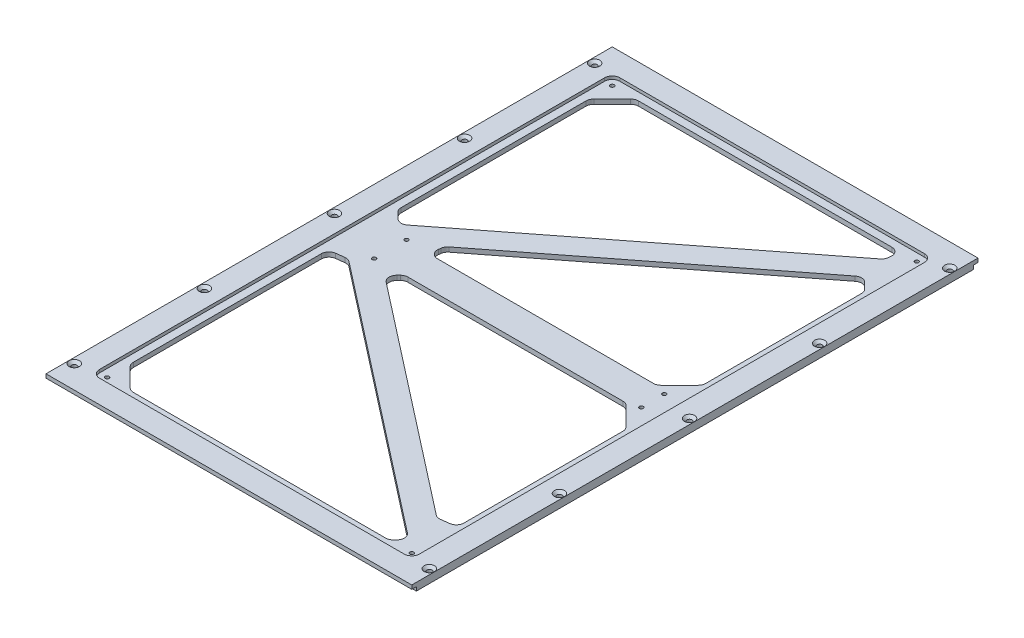
from build123d import *
from OCP.BRepFilletAPI import BRepFilletAPI_MakeChamfer

# Parameters (mm, degrees)
SKETCH1_W                                            = 239
SKETCH1_H                                            = 370
BOSS_EXTRUDE1_DEPTH                                  = 5
CSK_FOR_M3_HEX_SOCKET_COUNTERSUNK_CAP_SC_D           = 3.4
CSK_FOR_M3_HEX_SOCKET_COUNTERSUNK_CAP_SC_CSINK_D     = 6.72
CSK_FOR_M3_HEX_SOCKET_COUNTERSUNK_CAP_SC_CSINK_ANGLE = 90
SKETCH12_W                                           = 239
SKETCH12_H                                           = 3
CUT_EXTRUDE7_DEPTH                                   = 2.5
CUT_EXTRUDE8_DEPTH                                   = 441.506526626
CHAMFER1_SIZE                                        = 15
CHAMFER1_SIZE2                                       = 10.688218108
FILLET1_R                                            = 5
SKETCH14_W                                           = 209
SKETCH14_H                                           = 340
CUT_EXTRUDE9_DEPTH                                   = 2
FILLET2_R                                            = 5
M3_TAPPED_HOLE1_D                                    = 2.5
M3_TAPPED_HOLE1_DEPTH                                = 15
M3_TAPPED_HOLE1_TIP                                  = 0.751075774


with BuildPart() as part:
    # Sketch1 → Boss-Extrude1 (new body)
    with BuildSketch(Plane(origin=(0, 0, 0), x_dir=(1, 0, 0), z_dir=(0, 1, 0))):
        with Locations((-119.5, 185)):
            Rectangle(SKETCH1_W, SKETCH1_H)
    extrude(amount=BOSS_EXTRUDE1_DEPTH)

    # CSK for M3 Hex Socket Countersunk Cap Screw1 (through all)
    with Locations(Plane(origin=(0, 5, 0), x_dir=(1, 0, 0), z_dir=(0, 1, 0))):
        with Locations((-3.5, 15), (-3.5, 100), (-3.5, 185), (-3.5, 270), (-3.5, 355)):
            csk_for_m3_hex_socket_countersunk_cap_sc = CounterSinkHole(CSK_FOR_M3_HEX_SOCKET_COUNTERSUNK_CAP_SC_D / 2, CSK_FOR_M3_HEX_SOCKET_COUNTERSUNK_CAP_SC_CSINK_D / 2, counter_sink_angle=CSK_FOR_M3_HEX_SOCKET_COUNTERSUNK_CAP_SC_CSINK_ANGLE)

    # Mirror1: CSK for M3 Hex Socket Countersunk Cap Screw1 across plane
    add(csk_for_m3_hex_socket_countersunk_cap_sc.mirror(Plane.ZY.offset(119.5)), mode=Mode.SUBTRACT)

    # Sketch12 → Cut-Extrude7 (cut)
    with BuildSketch(Plane.XZ):
        with Locations((-119.5, -1.5)):
            Rectangle(SKETCH12_W, SKETCH12_H)
        with Locations((-119.5, -368.5)):
            Rectangle(SKETCH12_W, SKETCH12_H)
    extrude(amount=-CUT_EXTRUDE7_DEPTH, mode=Mode.SUBTRACT)

    # Sketch13 → Cut-Extrude8 (cut, through all)
    with BuildSketch(Plane(origin=(0, 5, 0), x_dir=(1, 0, 0), z_dir=(0, 1, 0))):
        Polygon((-20, 39.013212111), (-20, 175), (-194.589488967, 175), align=None)
        Polygon((-20, 350), (-219, 350), (-219, 195), align=None)
        Polygon((-20, 330.986787889), (-20, 195), (-194.589488967, 195), align=None)
        Polygon((-219, 20), (-219, 175), (-20, 20), align=None)
    extrude(amount=-CUT_EXTRUDE8_DEPTH, mode=Mode.SUBTRACT)

    # Chamfer1: one chamfer whose edges measure the first distance from different faces: ONE call of the kernel's chamfer builder (chamfer() names one face for all edges)
    chamfer1_edges_1 = [part.edges().sort_by_distance(p)[0] for p in [
        (-20, 2.5, -20),
    ]]
    chamfer1_side_1 = [part.faces().sort_by_distance(p)[0] for p in [
        (-119.5, 2.5, -20),
    ]]
    chamfer1_edges_2 = [part.edges().sort_by_distance(p)[0] for p in [
        (-219, 2.5, -20),
        (-20, 2.5, -175),
        (-219, 2.5, -350),
        (-20, 2.5, -195),
    ]]
    chamfer1_edges_3 = [part.edges().sort_by_distance(p)[0] for p in [
        (-219, 2.5, -175),
    ]]
    chamfer1_side_3 = [part.faces().sort_by_distance(p)[0] for p in [
        (-119.5, 2.5, -97.5),
    ]]
    chamfer1_edges_4 = [part.edges().sort_by_distance(p)[0] for p in [
        (-194.589488967, 2.5, -175),
    ]]
    chamfer1_side_4 = [part.faces().sort_by_distance(p)[0] for p in [
        (-107.294744483, 2.5, -175),
    ]]
    chamfer1_edges_5 = [part.edges().sort_by_distance(p)[0] for p in [
        (-20, 2.5, -39.013212111),
    ]]
    chamfer1_side_5 = [part.faces().sort_by_distance(p)[0] for p in [
        (-107.294744483, 2.5, -107.006606056),
    ]]
    chamfer1_edges_6 = [part.edges().sort_by_distance(p)[0] for p in [
        (-20, 2.5, -350),
    ]]
    chamfer1_side_6 = [part.faces().sort_by_distance(p)[0] for p in [
        (-119.5, 2.5, -272.5),
    ]]
    chamfer1_edges_7 = [part.edges().sort_by_distance(p)[0] for p in [
        (-219, 2.5, -195),
    ]]
    chamfer1_side_7 = [part.faces().sort_by_distance(p)[0] for p in [
        (-219, 2.5, -272.5),
    ]]
    chamfer1_edges_8 = [part.edges().sort_by_distance(p)[0] for p in [
        (-194.589488967, 2.5, -195),
    ]]
    chamfer1_side_8 = [part.faces().sort_by_distance(p)[0] for p in [
        (-107.294744483, 2.5, -262.993393944),
    ]]
    chamfer1_edges_9 = [part.edges().sort_by_distance(p)[0] for p in [
        (-20, 2.5, -330.986787889),
    ]]
    chamfer1_side_9 = [part.faces().sort_by_distance(p)[0] for p in [
        (-20, 2.5, -262.993393944),
    ]]
    chamfer1 = BRepFilletAPI_MakeChamfer(part.part.solid().wrapped)
    for e in chamfer1_edges_1:
        chamfer1.Add(CHAMFER1_SIZE, CHAMFER1_SIZE2, e.wrapped, chamfer1_side_1[0].wrapped)  # the first distance lies on this face
    for e in chamfer1_edges_2:
        chamfer1.Add(CHAMFER1_SIZE, e.wrapped)
    for e in chamfer1_edges_3:
        chamfer1.Add(CHAMFER1_SIZE, CHAMFER1_SIZE2, e.wrapped, chamfer1_side_3[0].wrapped)  # the first distance lies on this face
    for e in chamfer1_edges_4:
        chamfer1.Add(CHAMFER1_SIZE, CHAMFER1_SIZE2, e.wrapped, chamfer1_side_4[0].wrapped)  # the first distance lies on this face
    for e in chamfer1_edges_5:
        chamfer1.Add(CHAMFER1_SIZE, CHAMFER1_SIZE2, e.wrapped, chamfer1_side_5[0].wrapped)  # the first distance lies on this face
    for e in chamfer1_edges_6:
        chamfer1.Add(CHAMFER1_SIZE, CHAMFER1_SIZE2, e.wrapped, chamfer1_side_6[0].wrapped)  # the first distance lies on this face
    for e in chamfer1_edges_7:
        chamfer1.Add(CHAMFER1_SIZE, CHAMFER1_SIZE2, e.wrapped, chamfer1_side_7[0].wrapped)  # the first distance lies on this face
    for e in chamfer1_edges_8:
        chamfer1.Add(CHAMFER1_SIZE, CHAMFER1_SIZE2, e.wrapped, chamfer1_side_8[0].wrapped)  # the first distance lies on this face
    for e in chamfer1_edges_9:
        chamfer1.Add(CHAMFER1_SIZE, CHAMFER1_SIZE2, e.wrapped, chamfer1_side_9[0].wrapped)  # the first distance lies on this face
    add(Compound.cast(chamfer1.Shape()), mode=Mode.REPLACE)

    # Fillet1
    fillet1_edges = [part.edges().sort_by_distance(p)[0] for p in [
        (-179.589488967, 2.5, -175),
        (-35, 2.5, -175),
        (-20, 2.5, -49.701430219),
        (-20, 2.5, -160),
        (-219, 2.5, -35),
        (-219, 2.5, -164.311781892),
        (-28.43220339, 2.5, -26.56779661),
        (-207.16612371, 2.5, -165.782659171),
        (-204, 2.5, -20),
        (-35, 2.5, -20),
        (-186.157285577, 2.5, -168.43220339),
        (-31.83387629, 2.5, -48.23055294),
        (-31.83387629, 2.5, -340.782659171),
        (-210.56779661, 2.5, -201.56779661),
        (-219, 2.5, -335),
        (-219, 2.5, -210),
        (-35, 2.5, -195),
        (-183.901270859, 2.5, -195),
        (-28.43220339, 2.5, -324.418991278),
        (-182.755612677, 2.5, -204.217340829),
        (-20, 2.5, -210),
        (-20, 2.5, -315.986787889),
        (-204, 2.5, -350),
        (-30.688218108, 2.5, -350),
    ]]
    fillet(fillet1_edges, radius=FILLET1_R)

    # Sketch14 → Cut-Extrude9 (cut)
    with BuildSketch(Plane(origin=(0, 5, 0), x_dir=(1, 0, 0), z_dir=(0, 1, 0))):
        with Locations((-119.5, 185)):
            Rectangle(SKETCH14_W, SKETCH14_H)
    extrude(amount=-CUT_EXTRUDE9_DEPTH, mode=Mode.SUBTRACT)

    # Fillet2
    fillet2_edges = [part.edges().sort_by_distance(p)[0] for p in [
        (-224, 4, -15),
        (-224, 4, -355),
        (-15, 4, -355),
        (-15, 4, -15),
    ]]
    fillet(fillet2_edges, radius=FILLET2_R)

    # M3 Tapped Hole1
    with Locations(Plane(origin=(0, 3, 0), x_dir=(1, 0, 0), z_dir=(0, 1, 0))):
        with Locations((-219, 350), (-20, 350), (-20, 20), (-27.5, 192.5), (-219, 20), (-27.5, 177.5), (-199, 195.577889447), (-199, 174.422110553)):
            Hole(M3_TAPPED_HOLE1_D / 2, depth=M3_TAPPED_HOLE1_DEPTH)
            with Locations((0, 0, -(M3_TAPPED_HOLE1_DEPTH + M3_TAPPED_HOLE1_TIP / 2))):  # 118° drill point
                Cone(0, M3_TAPPED_HOLE1_D / 2, M3_TAPPED_HOLE1_TIP, mode=Mode.SUBTRACT)


solid = part.part
